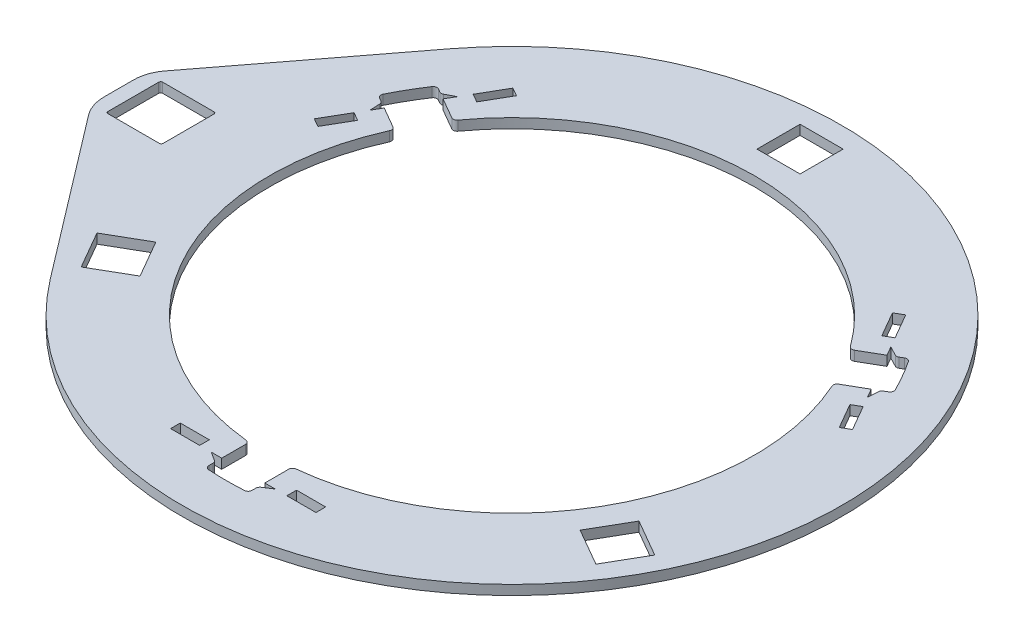
from build123d import *

# Parameters (mm, degrees)
SKETCH1_W           = 44.45
SKETCH1_H           = 44.45
SKETCH1_W_2         = 57
SKETCH1_H_2         = 56.4
BOSS_EXTRUDE1_DEPTH = 10
CUT_EXTRUDE1_DEPTH  = 10
CIRPATTERN1_COUNT   = 3
BOSS_EXTRUDE2_DEPTH = 10
CIRPATTERN2_COUNT   = 3
SKETCH7_W           = 30
SKETCH7_H           = 10
CUT_EXTRUDE2_DEPTH  = 10
CIRPATTERN3_COUNT   = 3
FILLET1_R           = 4
FILLET2_R           = 2


with BuildPart() as part:
    # Sketch1 → Boss-Extrude1 (new body)
    with BuildSketch(Plane(origin=(0, 82.464823413, 0), x_dir=(1, 0, 0), z_dir=(0, 1, 0))):
        with BuildLine():
            Line((-412.957473883, 60.178595798), (-412.957473883, 29.92539468))
            ThreePointArc((-412.957473883, 29.92539468), (-410.854889329, 17.127508038), (-404.768178759, 5.675053336))
            Line((-404.768178759, 5.675053336), (-277.648465327, -161.075906186))
            ThreePointArc((-277.648465327, -161.075906186), (332.742526117, 45.051995239), (-277.648465327, 251.179896664))
            Line((-277.648465327, 251.179896664), (-404.768178759, 84.428937143))
            ThreePointArc((-404.768178759, 84.428937143), (-410.854889329, 72.97648244), (-412.957473883, 60.178595798))
        make_face()
        with BuildLine():
            ThreePointArc((-234.019080144, 150.30965019), (-223.763824829, -79.948004761), (-29.482473883, -203.958143862))
            Line((-29.482473883, -203.958143862), (-29.482473883, -262.248004761))
            Line((-29.482473883, -262.248004761), (14.967526117, -262.248004761))
            Line((14.967526117, -262.248004761), (14.967526117, -203.958143862))
            ThreePointArc((14.967526117, -203.958143862), (209.248877063, -79.948004761), (219.504132378, 150.30965019))
            Line((219.504132378, 150.30965019), (269.9846327, 179.45458064))
            Line((269.9846327, 179.45458064), (247.7596327, 217.949409838))
            Line((247.7596327, 217.949409838), (197.279132378, 188.804479389))
            ThreePointArc((197.279132378, 188.804479389), (-7.257473883, 295.051995239), (-211.794080144, 188.804479389))
            Line((-211.794080144, 188.804479389), (-262.274580466, 217.949409838))
            Line((-262.274580466, 217.949409838), (-284.499580466, 179.45458064))
            Line((-284.499580466, 179.45458064), (-234.019080144, 150.30965019))
        make_face(mode=Mode.SUBTRACT)
        with Locations((-7.257473883, 342.276995239)):
            Rectangle(SKETCH1_W, SKETCH1_H, mode=Mode.SUBTRACT)
        Polygon((-272.796789122, -133.92041936), (-234.301959924, -111.69541936), (-256.526959924, -73.200590162), (-295.021789122, -95.425590162), align=None, mode=Mode.SUBTRACT)
        with Locations((-369.457473883, 45.051995239)):
            Rectangle(SKETCH1_W_2, SKETCH1_H_2, mode=Mode.SUBTRACT)
        Polygon((219.787012158, -111.69541936), (258.281841356, -133.92041936), (280.506841356, -95.425590162), (242.012012158, -73.200590162), align=None, mode=Mode.SUBTRACT)
    extrude(amount=-BOSS_EXTRUDE1_DEPTH)

    # Sketch5 → Cut-Extrude1 (cut)
    with BuildSketch(Plane(origin=(0, 82.464823413, 0), x_dir=(1, 0, 0), z_dir=(0, 1, 0))):
        Polygon((14.967526117, -239.202482577), (25.746966731, -232.248004761), (14.967526117, -232.248004761), align=None)
        Polygon((-40.261914497, -232.248004761), (-29.482473883, -232.248004761), (-29.482473883, -239.202482577), align=None)
    cut_extrude1 = extrude(amount=-CUT_EXTRUDE1_DEPTH, mode=Mode.SUBTRACT)

    # CirPattern1: Cut-Extrude1 ×3 about axis
    cirpattern1_axis = Axis((-7.257473883, 0, -45.051995239), (0, 1, 0))
    for i in range(1, CIRPATTERN1_COUNT):
        add(cut_extrude1.rotate(cirpattern1_axis, i * 360 / CIRPATTERN1_COUNT), mode=Mode.SUBTRACT)

    # Sketch6 → Boss-Extrude2 (add)
    with BuildSketch(Plane(origin=(0, 82.464823413, 0), x_dir=(1, 0, 0), z_dir=(0, 1, 0))):
        with BuildLine():
            Line((-29.482473883, -249.109608943), (-29.482473883, -270.376708747))
            Line((-29.482473883, -270.376708747), (14.967526117, -270.376708747))
            Line((14.967526117, -270.376708747), (14.967526117, -249.109608943))
            ThreePointArc((14.967526117, -249.109608943), (-7.257473883, -249.948004761), (-29.482473883, -249.109608943))
        make_face()
    boss_extrude2 = extrude(amount=-BOSS_EXTRUDE2_DEPTH)

    # CirPattern2: Boss-Extrude2 ×3 about axis
    cirpattern2_axis = Axis((-7.257473883, 72.464823413, -45.051995239), (0, 1, 0))
    for i in range(1, CIRPATTERN2_COUNT):
        add(boss_extrude2.rotate(cirpattern2_axis, i * 360 / CIRPATTERN2_COUNT))

    # Sketch7 → Cut-Extrude2 (cut)
    with BuildSketch(Plane.XZ.offset(-72.464823413)):
        with Locations((52.742526117, 227.248004761)):
            Rectangle(SKETCH7_W, SKETCH7_H)
        with Locations((-67.257473883, 227.248004761)):
            Rectangle(SKETCH7_W, SKETCH7_H)
    cut_extrude2 = extrude(amount=-CUT_EXTRUDE2_DEPTH, mode=Mode.SUBTRACT)

    # CirPattern3: Cut-Extrude2 ×3 about axis
    cirpattern3_axis = Axis((-7.257473883, 0, -45.051995239), (0, 1, 0))
    for i in range(1, CIRPATTERN3_COUNT):
        add(cut_extrude2.rotate(cirpattern3_axis, i * 360 / CIRPATTERN3_COUNT), mode=Mode.SUBTRACT)

    # Fillet1
    fillet1_edges = [part.edges().sort_by_distance(p)[0] for p in [
        (-29.482473883, 77.464823413, 239.202482577),
        (14.967526117, 77.464823413, 239.202482577),
        (250.026625045, 77.464823413, -167.931819548),
        (227.801625045, 77.464823413, -206.426648746),
        (-242.316572811, 77.464823413, -206.426648746),
        (-264.541572811, 77.464823413, -167.931819548),
        (14.967526117, 77.464823413, 249.109608943),
        (-29.482473883, 77.464823413, 249.109608943),
        (258.606448157, 77.464823413, -172.885382731),
        (236.381448157, 77.464823413, -211.380211929),
        (-273.121395923, 77.464823413, -172.885382731),
        (-250.896395923, 77.464823413, -211.380211929),
        (-29.482473883, 77.464823413, 203.958143862),
        (14.967526117, 77.464823413, 203.958143862),
        (219.504132378, 77.464823413, -150.30965019),
        (197.279132378, 77.464823413, -188.804479389),
        (-211.794080144, 77.464823413, -188.804479389),
        (-234.019080144, 77.464823413, -150.30965019),
    ]]
    fillet(fillet1_edges, radius=FILLET1_R)

    # Fillet2
    fillet2_edges = [part.edges().sort_by_distance(p)[0] for p in [
        (-397.957473883, 77.464823413, -73.251995239),
        (-397.957473883, 77.464823413, -16.851995239),
        (-340.957473883, 77.464823413, -16.851995239),
        (-340.957473883, 77.464823413, -73.251995239),
    ]]
    fillet(fillet2_edges, radius=FILLET2_R)


solid = part.part
